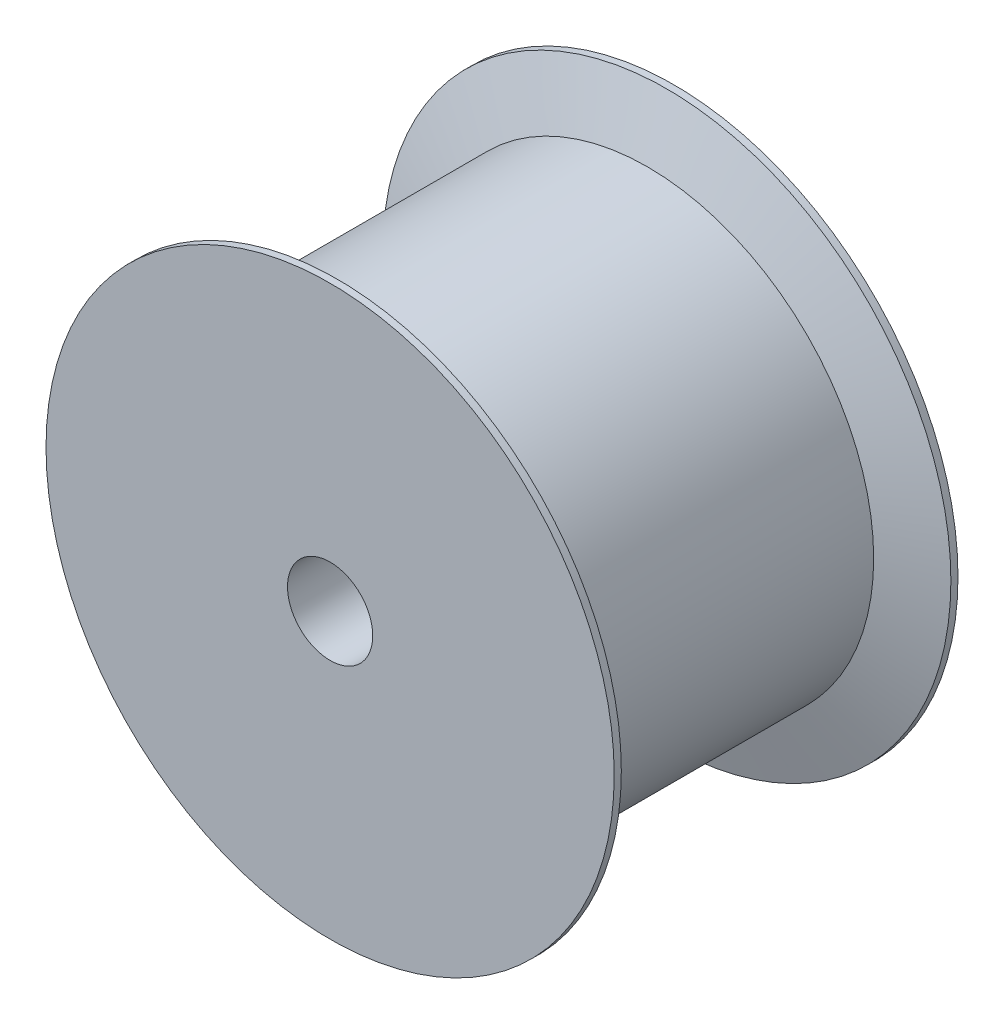
from build123d import *

# Parameters (mm, degrees)
SKETCH_3_R          = 3
CUT_EXTRUDE_1_DEPTH = 25.2


with BuildPart() as part:
    # 草圖2 → 旋轉1 (revolve)
    with BuildSketch(Plane(origin=(0, 0, 0), x_dir=(1, 0, 0), z_dir=(0, 1, 0))):
        Polygon((20, -0.5), (15.915, -1.85), (15.915, -22.35), (20, -23.7), (20, -24.2), (0, -24.2), (0, 0), (20, 0), align=None)
    revolve(axis=Axis((0, 0, 0), (0, 0, 1)))

    # 草圖3 → 除料-伸長1 (cut, through all)
    with BuildSketch(Plane.XY.offset(24.2)):
        Circle(SKETCH_3_R)
    extrude(amount=-CUT_EXTRUDE_1_DEPTH, mode=Mode.SUBTRACT)


solid = part.part
